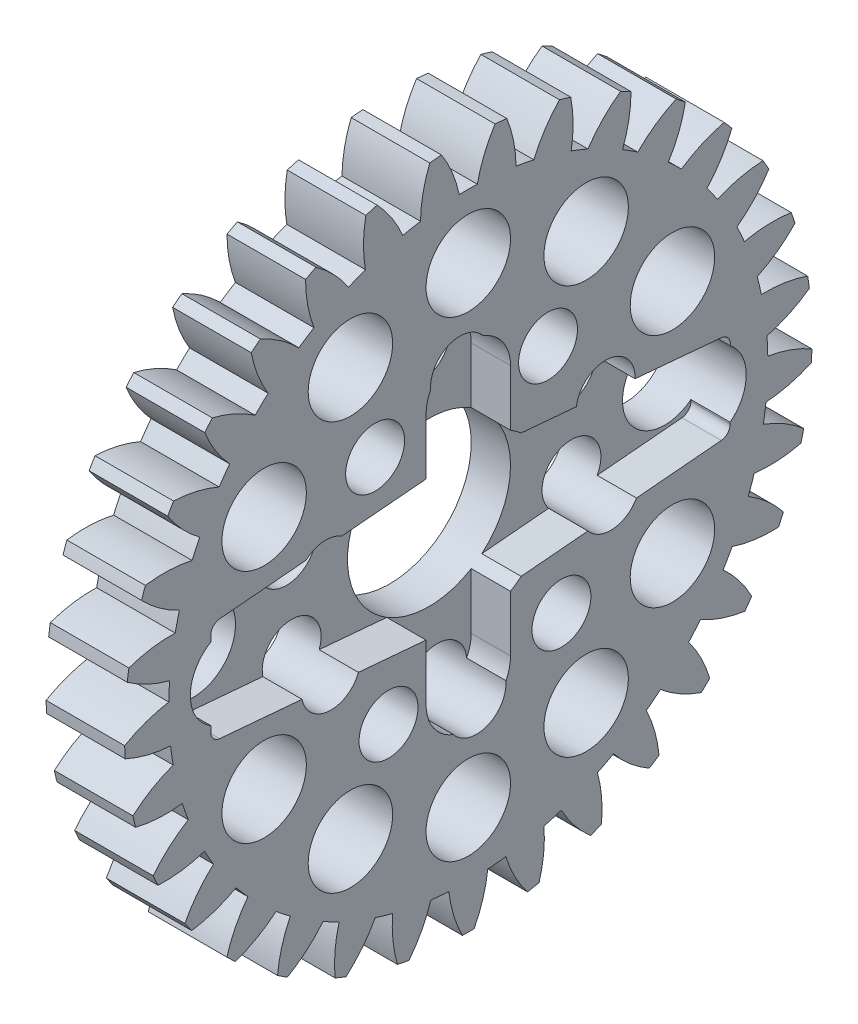
from build123d import *

# Parameters (mm, degrees)
BASPROSKE_W                     = 4
BASPROSKE_H                     = 17.5
TOOTHCUT_DEPTH                  = 26.069902273
TEETHCUTS_COUNT                 = 33
TEETHCUTS_ANGLE                 = 349.090909091
BORSKE_R                        = 1.5
BORE_DEPTH                      = 50.0000508
FLAP_DEPTH                      = 2
FLAP_2_DEPTH                    = 2
FLAP_3_DEPTH                    = 2
BORE_8_3_R                      = 4.15
BORE8_3_DEPTH                   = 26.0642039
VERRUNDUNG1_R                   = 0.5
SKIZZE1_R                       = 2.15
SCHNITT_LINEAR_AUSTRAGEN1_DEPTH = 26.0642039
KREISMUSTER1_COUNT              = 12
SKIZZE2_R                       = 1.5
SCHNITT_LINEAR_AUSTRAGEN2_DEPTH = 26.0642039
KREISMUSTER2_COUNT              = 10


with BuildPart() as part:
    # BasProSke → Base-Revolve (revolve)
    with BuildSketch(Plane(origin=(0, 0, 0), x_dir=(1, 0, 0), z_dir=(0, 1, 0)), mode=Mode.PRIVATE) as base_revolve_sk:
        with Locations((2, 8.75)):
            Rectangle(BASPROSKE_W, BASPROSKE_H)
    revolve(base_revolve_sk.sketch.rotate(Axis((-10, 0, 0), (1, 0, 0)), 180), axis=Axis((-10, 0, 0), (1, 0, 0)))

    # TooCutSke → ToothCut (cut, through all)
    with BuildSketch(Plane(origin=(0, 0, 0), x_dir=(0, 0, -1), z_dir=(1, 0, 0))):
        with BuildLine():
            ThreePointArc((0.460038855, 15.242059088), (0, 15.249), (-0.460038855, 15.242059088))
            ThreePointArc((-0.460038855, 15.242059088), (-0.818271128, 16.398913356), (-1.381851371, 17.470836613))
            ThreePointArc((-1.381851371, 17.470836613), (0, 17.5254), (1.381851371, 17.470836613))
            ThreePointArc((1.381851371, 17.470836613), (0.818271128, 16.398913356), (0.460038855, 15.242059088))
        make_face()
    toothcut = extrude(amount=TOOTHCUT_DEPTH, mode=Mode.SUBTRACT)

    # TeethCuts: ToothCut ×33 about axis
    teethcuts_axis = Axis((-10, 0, 0), (1, 0, 0))
    for i in range(1, TEETHCUTS_COUNT):
        add(toothcut.rotate(teethcuts_axis, i * TEETHCUTS_ANGLE / (TEETHCUTS_COUNT - 1)), mode=Mode.SUBTRACT)

    # BorSke → Bore (cut, symmetric)
    with BuildSketch(Plane(origin=(0, 0, 0), x_dir=(0, 0, -1), z_dir=(1, 0, 0))):
        with Locations(Location((0, 0, 0), (0, 0, 180))):
            Circle(BORSKE_R)
    extrude(amount=BORE_DEPTH, both=True, mode=Mode.SUBTRACT)

    # flap2 → flap (cut)
    with BuildSketch(Plane(origin=(4, 0, 0), x_dir=(0, 0, -1), z_dir=(1, 0, 0))):
        with BuildLine():
            Line((2.15, 6.4), (2.15, -6.4))
            ThreePointArc((2.15, -6.4), (0, -8.55), (-2.15, -6.4))
            Line((-2.15, -6.4), (-2.15, 6.4))
            ThreePointArc((-2.15, 6.4), (0, 8.55), (2.15, 6.4))
        make_face()
    extrude(amount=-FLAP_DEPTH, mode=Mode.SUBTRACT)

    # flap2 2 → flap-2 (cut)
    with BuildSketch(Plane(origin=(4, 0, 0), x_dir=(0, 0, -1), z_dir=(1, 0, 0))):
        Polygon((-2.15, 3.54964787), (-13.10930479, 2.604323307), (-13.10930479, -2.604323307), (-2.15, -3.54964787), align=None)
    extrude(amount=-FLAP_2_DEPTH, mode=Mode.SUBTRACT)

    # flap3 → flap-3 (cut)
    with BuildSketch(Plane(origin=(4, 0, 0), x_dir=(0, 0, -1), z_dir=(1, 0, 0))):
        Polygon((2.690148695, -3.16), (13.331961736, -2.223347052), (13.340672985, 2.22258032), (2.690148695, 3.16), align=None)
    extrude(amount=-FLAP_3_DEPTH, mode=Mode.SUBTRACT)

    # bore-8.3 → bore8.3 (cut, through all)
    with BuildSketch(Plane(origin=(4, 0, 0), x_dir=(0, 0, -1), z_dir=(1, 0, 0))):
        Circle(BORE_8_3_R)
    extrude(amount=-BORE8_3_DEPTH, mode=Mode.SUBTRACT)

    # Verrundung1
    verrundung1_edges = [part.edges().sort_by_distance(p)[0] for p in [
        (3, -2.604323307, 13.10930479),
        (3, 2.604323307, 13.10930479),
        (3, 2.22258032, -13.340672985),
        (3, -2.223347052, -13.331961736),
    ]]
    fillet(verrundung1_edges, radius=VERRUNDUNG1_R)

    # Skizze1 → Schnitt-Linear austragen1 (cut, through all)
    with BuildSketch(Plane(origin=(4, 0, 0), x_dir=(0, 0, -1), z_dir=(1, 0, 0))):
        with Locations((-12, 0)):
            Circle(SKIZZE1_R)
    schnitt_linear_austragen1 = extrude(amount=-SCHNITT_LINEAR_AUSTRAGEN1_DEPTH, mode=Mode.SUBTRACT)

    # Kreismuster1: Schnitt-Linear austragen1 ×12 about axis
    kreismuster1_axis = Axis((0, 0, 0), (1, 0, 0))
    for i in range(1, KREISMUSTER1_COUNT):
        add(schnitt_linear_austragen1.rotate(kreismuster1_axis, i * 360 / KREISMUSTER1_COUNT), mode=Mode.SUBTRACT)

    # Skizze2 → Schnitt-Linear austragen2 (cut, through all)
    with BuildSketch(Plane(origin=(4, 0, 0), x_dir=(0, 0, -1), z_dir=(1, 0, 0))):
        with Locations((-4.742352993, 5.810343199)):
            Circle(SKIZZE2_R)
    schnitt_linear_austragen2 = extrude(amount=-SCHNITT_LINEAR_AUSTRAGEN2_DEPTH, mode=Mode.SUBTRACT)

    # Kreismuster2: Schnitt-Linear austragen2 ×10 about axis
    kreismuster2_axis = Axis((0, 0, 0), (1, 0, 0))
    for i in range(1, KREISMUSTER2_COUNT):
        add(schnitt_linear_austragen2.rotate(kreismuster2_axis, i * 360 / KREISMUSTER2_COUNT), mode=Mode.SUBTRACT)


solid = part.part
